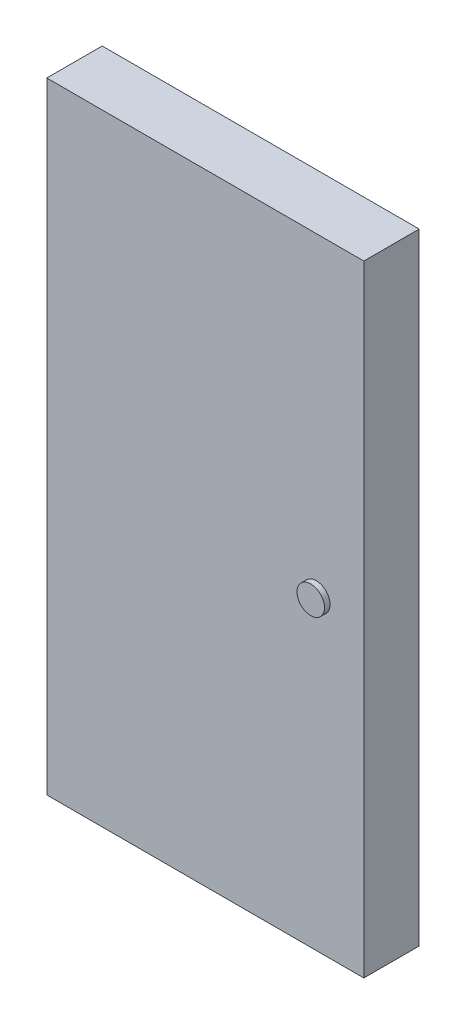
from build123d import *

# Parameters (mm, degrees)
CROQUIS1_W              = 1717.05
CROQUIS1_H              = 3362.83
SALIENTE_EXTRUIR1_DEPTH = 300
CROQUIS2_R              = 74.461295819
SALIENTE_EXTRUIR2_DEPTH = 30


with BuildPart() as part:
    # Croquis1 → Saliente-Extruir1 (new body)
    with BuildSketch(Plane.XY):
        with Locations((-601.130390599, 21.232337461)):
            Rectangle(CROQUIS1_W, CROQUIS1_H)
    extrude(amount=SALIENTE_EXTRUIR1_DEPTH)

    # Croquis2 → Saliente-Extruir2 (add)
    with BuildSketch(Plane.XY.offset(300)):
        Circle(CROQUIS2_R)
    extrude(amount=SALIENTE_EXTRUIR2_DEPTH)


solid = part.part
